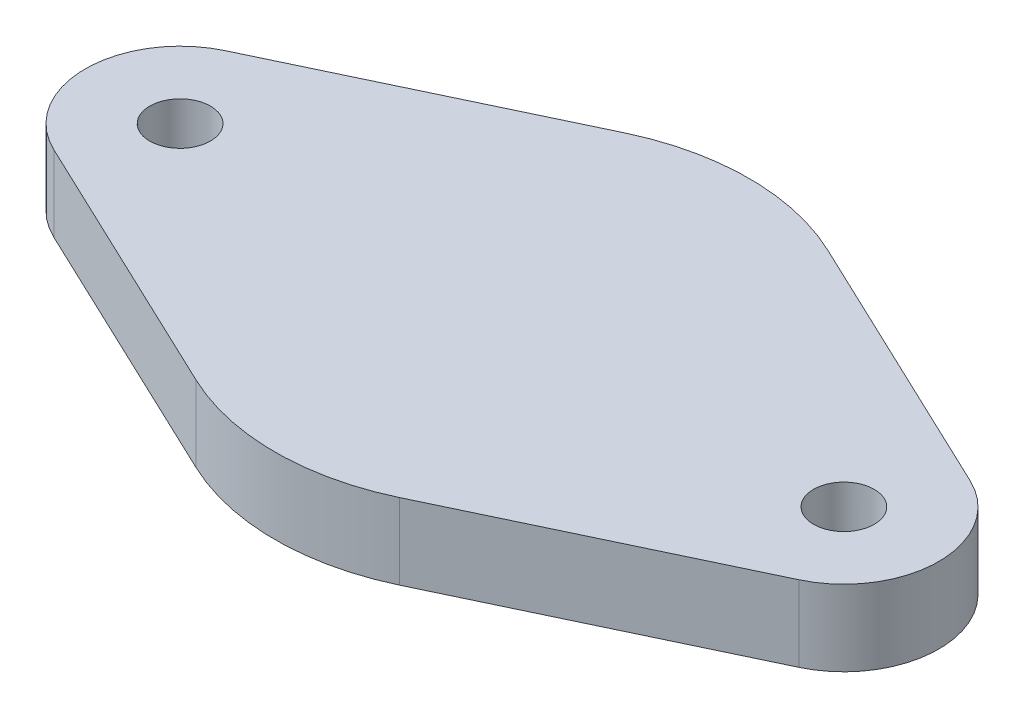
from build123d import *

# Parameters (mm, degrees)
SKETCH2_R           = 1.6
BOSS_EXTRUDE1_DEPTH = 4


with BuildPart() as part:
    # Sketch1 → Revolve2 (revolve)
    with BuildSketch(Plane.XY):
        with BuildLine():
            ThreePointArc((6.530888148, 7.9), (3.470410639, 9.644622854), (0, 10.25))
            Line((0, 10.25), (0, 11.9))
            Line((0, 11.9), (12.5, 11.9))
            Line((12.5, 11.9), (12.5, 7.9))
            Line((12.5, 7.9), (6.530888148, 7.9))
        make_face()
    revolve(axis=Axis((0, 12.495, 0), (0, -1, 0)))

    # Sketch2 → Boss-Extrude1 (add)
    with BuildSketch(Plane(origin=(0, 11.9, 0), x_dir=(1, 0, 0), z_dir=(0, 1, 0))):
        with BuildLine():
            Line((-5.357142857, 11.293848786), (-19.642857143, 4.517539515))
            ThreePointArc((-19.642857143, 4.517539515), (-22.5, 0), (-19.642857143, -4.517539515))
            Line((-19.642857143, -4.517539515), (-5.357142857, -11.293848786))
            ThreePointArc((-5.357142857, -11.293848786), (-12.5, 0), (-5.357142857, 11.293848786))
        make_face()
        with Locations((-17.5, 0)):
            Circle(SKETCH2_R, mode=Mode.SUBTRACT)
        with BuildLine():
            Line((5.357142857, -11.293848786), (19.642857143, -4.517539515))
            ThreePointArc((19.642857143, -4.517539515), (22.5, 0), (19.642857143, 4.517539515))
            Line((19.642857143, 4.517539515), (5.357142857, 11.293848786))
            ThreePointArc((5.357142857, 11.293848786), (12.5, 0), (5.357142857, -11.293848786))
        make_face()
        with Locations((17.5, 0)):
            Circle(SKETCH2_R, mode=Mode.SUBTRACT)
    extrude(amount=-BOSS_EXTRUDE1_DEPTH)


solid = part.part
